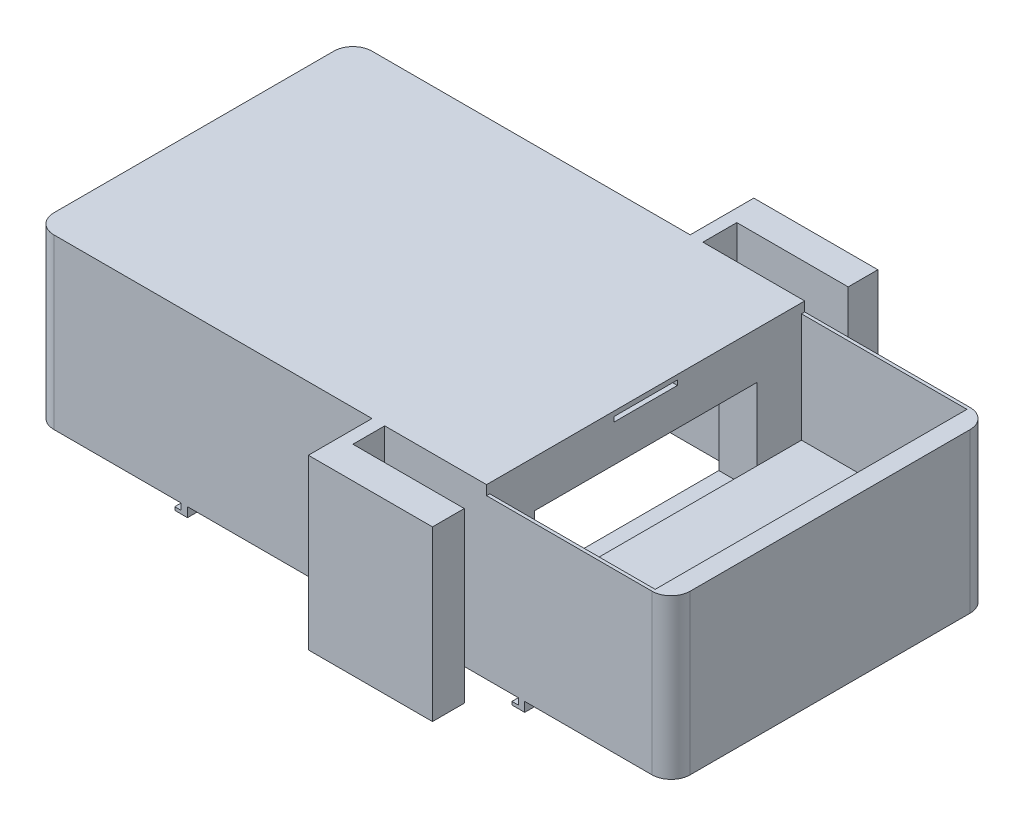
from build123d import *

# Parameters (mm, degrees)
BOSS_EXTRUDE1_DEPTH  = 25
SKETCH3_W            = 26
SKETCH3_H            = 49
CUT_EXTRUDE1_DEPTH   = 17.2
SKETCH4_W            = 62
SKETCH4_H            = 46
CUT_EXTRUDE2_DEPTH   = 22
SKETCH5_W            = 2
SKETCH5_H            = 20
CUT_EXTRUDE4_DEPTH   = 3
SKETCH6_W            = 23
SKETCH6_H            = 15
CUT_EXTRUDE5_DEPTH   = 2
SKETCH7_W            = 35
SKETCH7_H            = 15
CUT_EXTRUDE6_DEPTH   = 6
BOSS_EXTRUDE2_DEPTH  = 1.5
SKETCH9_W            = 10
SKETCH9_H            = 0.75
CUT_EXTRUDE7_DEPTH   = 7.5
SKETCH10_W           = 1
SKETCH10_H           = 2
BOSS_EXTRUDE3_DEPTH  = 1.5
SKETCH11_W           = 1
SKETCH11_H           = 2
BOSS_EXTRUDE4_DEPTH  = 1.5
SKETCH12_W           = 2
SKETCH12_H           = 0.5
BOSS_EXTRUDE5_DEPTH  = 1
SKETCH13_W           = 2
SKETCH13_H           = 0.5
BOSS_EXTRUDE6_DEPTH  = 1
SKETCH14_W           = 2
SKETCH14_H           = 0.5
BOSS_EXTRUDE7_DEPTH  = 1
SKETCH15_W           = 2
SKETCH15_H           = 0.5
BOSS_EXTRUDE8_DEPTH  = 1
SKETCH17_W           = 2
SKETCH17_H           = 26.5
BOSS_EXTRUDE10_DEPTH = 10
SKETCH18_W           = 2
SKETCH18_H           = 26.5
BOSS_EXTRUDE11_DEPTH = 10
SKETCH19_W           = 5
SKETCH19_H           = 26.5
SKETCH19_W_2         = 4.66783526
BOSS_EXTRUDE13_DEPTH = 17.5
SKETCH20_R           = 2.5
BOSS_EXTRUDE14_DEPTH = 7
SKETCH21_R           = 1.5
CUT_EXTRUDE8_DEPTH   = 5


with BuildPart() as part:
    # Sketch2 → Boss-Extrude1 (new body)
    with BuildSketch(Plane(origin=(0, 0, 0), x_dir=(1, 0, 0), z_dir=(0, 1, 0))):
        with BuildLine():
            Line((47, -25), (-47, -25))
            ThreePointArc((-47, -25), (-49.121320344, -24.121320344), (-50, -22))
            Line((-50, -22), (-50, 22))
            ThreePointArc((-50, 22), (-49.121320344, 24.121320344), (-47, 25))
            Line((-47, 25), (47, 25))
            ThreePointArc((47, 25), (49.121320344, 24.121320344), (50, 22))
            Line((50, 22), (50, -22))
            ThreePointArc((50, -22), (49.121320344, -24.121320344), (47, -25))
        make_face()
    extrude(amount=BOSS_EXTRUDE1_DEPTH)

    # Sketch3 → Cut-Extrude1 (cut)
    with BuildSketch(Plane(origin=(0, 25, 0), x_dir=(1, 0, 0), z_dir=(0, 1, 0))):
        with Locations((34, 0)):
            Rectangle(SKETCH3_W, SKETCH3_H)
    extrude(amount=-CUT_EXTRUDE1_DEPTH, mode=Mode.SUBTRACT)

    # Sketch4 → Cut-Extrude2 (cut)
    with BuildSketch(Plane.XZ):
        with Locations((-16, 0)):
            Rectangle(SKETCH4_W, SKETCH4_H)
    extrude(amount=-CUT_EXTRUDE2_DEPTH, mode=Mode.SUBTRACT)

    # Sketch5 → Cut-Extrude4 (cut)
    with BuildSketch(Plane.ZY.offset(50)):
        with Locations((-8.75, 12.5)):
            Rectangle(SKETCH5_W, SKETCH5_H)
        with Locations((-5.25, 12.5)):
            Rectangle(SKETCH5_W, SKETCH5_H)
        with Locations((-1.75, 12.5)):
            Rectangle(SKETCH5_W, SKETCH5_H)
        with Locations((1.75, 12.5)):
            Rectangle(SKETCH5_W, SKETCH5_H)
        with Locations((5.25, 12.5)):
            Rectangle(SKETCH5_W, SKETCH5_H)
        with Locations((8.75, 12.5)):
            Rectangle(SKETCH5_W, SKETCH5_H)
    extrude(amount=-CUT_EXTRUDE4_DEPTH, mode=Mode.SUBTRACT)

    # Sketch6 → Cut-Extrude5 (cut)
    with BuildSketch(Plane(origin=(0, 0, -25), x_dir=(-1, 0, 0), z_dir=(0, 0, -1))):
        with Locations((33.5, 15.101074808)):
            Rectangle(SKETCH6_W, SKETCH6_H)
    extrude(amount=-CUT_EXTRUDE5_DEPTH, mode=Mode.SUBTRACT)

    # Sketch7 → Cut-Extrude6 (cut)
    with BuildSketch(Plane.ZY.offset(-15)):
        with Locations((0, 11.669015381)):
            Rectangle(SKETCH7_W, SKETCH7_H)
    extrude(amount=-CUT_EXTRUDE6_DEPTH, mode=Mode.SUBTRACT)

    # Sketch8 → Boss-Extrude2 (add)
    with BuildSketch(Plane(origin=(0, 25, 0), x_dir=(1, 0, 0), z_dir=(0, 1, 0))):
        with BuildLine():
            Line((-47, 25), (21, 25))
            Line((21, 25), (21, -25))
            Line((21, -25), (-47, -25))
            ThreePointArc((-47, -25), (-49.121320344, -24.121320344), (-50, -22))
            Line((-50, -22), (-50, 22))
            ThreePointArc((-50, 22), (-49.121320344, 24.121320344), (-47, 25))
        make_face()
    extrude(amount=BOSS_EXTRUDE2_DEPTH)

    # Sketch9 → Cut-Extrude7 (cut)
    with BuildSketch(Plane(origin=(21, 0, 0), x_dir=(0, 0, -1), z_dir=(1, 0, 0))):
        with Locations((0, 25.375)):
            Rectangle(SKETCH9_W, SKETCH9_H)
    extrude(amount=-CUT_EXTRUDE7_DEPTH, mode=Mode.SUBTRACT)

    # Sketch10 → Boss-Extrude3 (add)
    with BuildSketch(Plane.XZ):
        with Locations((-26.5, 24)):
            Rectangle(SKETCH10_W, SKETCH10_H)
    extrude(amount=BOSS_EXTRUDE3_DEPTH)

    # Sketch11 → Boss-Extrude4 (add)
    with BuildSketch(Plane.XZ):
        with Locations((-26.5, -24)):
            Rectangle(SKETCH11_W, SKETCH11_H)
        with Locations((26.5, 24)):
            Rectangle(SKETCH11_W, SKETCH11_H)
        with Locations((26.5, -24)):
            Rectangle(SKETCH11_W, SKETCH11_H)
    extrude(amount=BOSS_EXTRUDE4_DEPTH)

    # Sketch12 → Boss-Extrude5 (add)
    with BuildSketch(Plane.ZY.offset(27)):
        with Locations((24, -1.25)):
            Rectangle(SKETCH12_W, SKETCH12_H)
    extrude(amount=BOSS_EXTRUDE5_DEPTH)

    # Sketch13 → Boss-Extrude6 (add)
    with BuildSketch(Plane.ZY.offset(27)):
        with Locations((-24, -1.25)):
            Rectangle(SKETCH13_W, SKETCH13_H)
    extrude(amount=BOSS_EXTRUDE6_DEPTH)

    # Sketch14 → Boss-Extrude7 (add)
    with BuildSketch(Plane.ZY.offset(-26)):
        with Locations((-24, -1.25)):
            Rectangle(SKETCH14_W, SKETCH14_H)
    extrude(amount=BOSS_EXTRUDE7_DEPTH)

    # Sketch15 → Boss-Extrude8 (add)
    with BuildSketch(Plane.ZY.offset(-26)):
        with Locations((24, -1.25)):
            Rectangle(SKETCH15_W, SKETCH15_H)
    extrude(amount=BOSS_EXTRUDE8_DEPTH)

    # Sketch17 → Boss-Extrude10 (add)
    with BuildSketch(Plane.XY.offset(25)):
        with Locations((4, 13.25)):
            Rectangle(SKETCH17_W, SKETCH17_H)
    extrude(amount=BOSS_EXTRUDE10_DEPTH)

    # Sketch18 → Boss-Extrude11 (add)
    with BuildSketch(Plane(origin=(0, 0, -25), x_dir=(-1, 0, 0), z_dir=(0, 0, -1))):
        with Locations((-4, 13.25)):
            Rectangle(SKETCH18_W, SKETCH18_H)
    extrude(amount=BOSS_EXTRUDE11_DEPTH)

    # Sketch19 → Boss-Extrude13 (add)
    with BuildSketch(Plane(origin=(5, 0, 0), x_dir=(0, 0, -1), z_dir=(1, 0, 0))):
        with Locations((-32.5, 13.25)):
            Rectangle(SKETCH19_W, SKETCH19_H)
        with Locations((32.66608237, 13.25)):
            Rectangle(SKETCH19_W_2, SKETCH19_H)
    extrude(amount=BOSS_EXTRUDE13_DEPTH)

    # Sketch20 → Boss-Extrude14 (add)
    with BuildSketch(Plane.XZ.offset(-22)):
        with Locations((-40.5, 11.075)):
            Circle(SKETCH20_R)
        with Locations((8.5, 11.075)):
            Circle(SKETCH20_R)
        with Locations((-40.5, -11.075)):
            Circle(SKETCH20_R)
        with Locations((8.5, -11.075)):
            Circle(SKETCH20_R)
    extrude(amount=BOSS_EXTRUDE14_DEPTH)

    # Sketch21 → Cut-Extrude8 (cut)
    with BuildSketch(Plane(origin=(0, 15, 0), x_dir=(-1, 0, 0), z_dir=(0, -1, 0))):
        with Locations((-8.5, 11.075)):
            Circle(SKETCH21_R)
        with Locations((-8.5, -11.075)):
            Circle(SKETCH21_R)
        with Locations((40.5, 11.075)):
            Circle(SKETCH21_R)
        with Locations((40.5, -11.075)):
            Circle(SKETCH21_R)
    extrude(amount=-CUT_EXTRUDE8_DEPTH, mode=Mode.SUBTRACT)


solid = part.part
